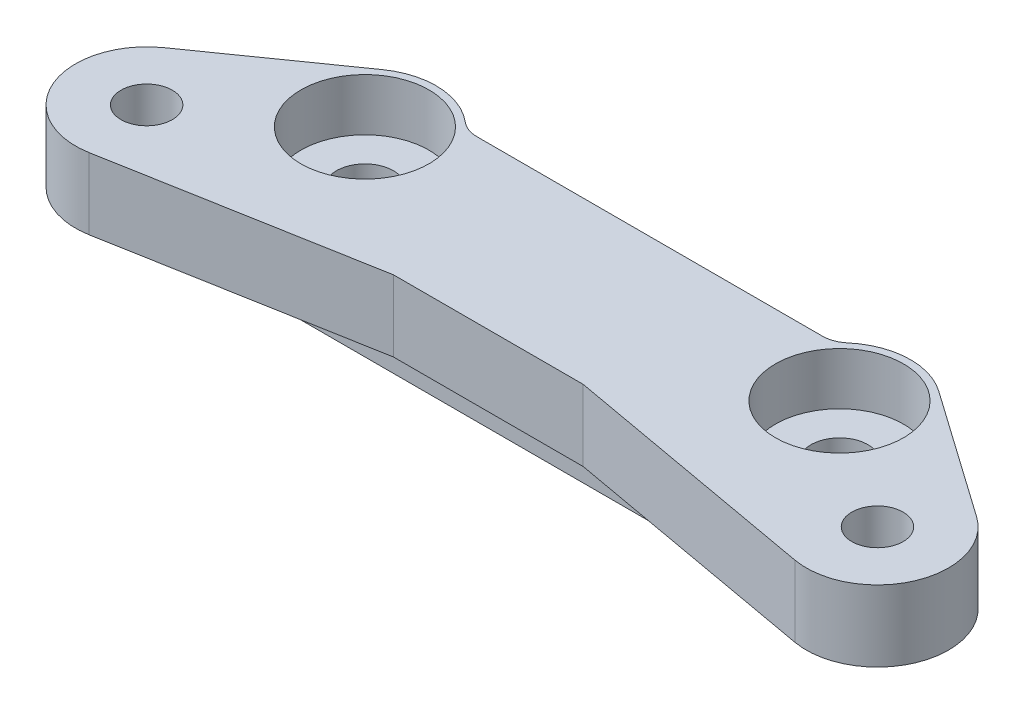
from build123d import *
from build123d.topology import SkipClean

# Parameters (mm, degrees)
BOSS_EXTRU_1_DEPTH      = 27
ESQUISSE1_3_R           = 15
ENL_V_MAT_EXTRU_1_DEPTH = 12
TROU_TARAUD_M12X1_251_D = 10.8
PER_AGE1_D              = 12
PER_AGE1_DEPTH          = 27
PER_AGE1_CBORE_D        = 27
PER_AGE1_CBORE_DEPTH    = 11
PER_AGE1_TIP            = 3.605163714
CONG_1_R                = 6


with BuildPart() as part:
    # Esquisse1 → Boss.-Extru.1 (new body)
    with BuildSketch(Plane(origin=(0, 0, 0), x_dir=(1, 0, 0), z_dir=(0, 1, 0))):
        with BuildLine():
            Line((-74.347688243, -14.763645971), (-20, -5))
            Line((-20, -5), (20, -5))
            Line((20, -5), (74.347688243, -14.763645971))
            ThreePointArc((74.347688243, -14.763645971), (90.842168324, -5.778786733), (85.632401093, 12.26709629))
            Line((85.632401093, 12.26709629), (58.632401093, 31.26709629))
            ThreePointArc((58.632401093, 31.26709629), (48.294734794, 33.902753792), (38.819660113, 29))
            Line((38.819660113, 29), (-38.819660113, 29))
            ThreePointArc((-38.819660113, 29), (-48.294734794, 33.902753792), (-58.632401093, 31.26709629))
            Line((-58.632401093, 31.26709629), (-85.632401093, 12.26709629))
            ThreePointArc((-85.632401093, 12.26709629), (-90.842168324, -5.778786733), (-74.347688243, -14.763645971))
        make_face()
    extrude(amount=BOSS_EXTRU_1_DEPTH)

    # Esquisse1_3 → Enl_v. mat.-Extru.1 (cut)
    with SkipClean():  # keep this step's faces unmerged: merging them makes the solid invalid here
        with BuildSketch(Plane(origin=(0, 0, 0), x_dir=(1, 0, 0), z_dir=(0, 1, 0))):
            with BuildLine():
                Line((-74.347688243, -14.763645971), (-20, -5))
                Line((-20, -5), (0, -5))
                Line((0, -5), (20, -5))
                Line((20, -5), (74.347688243, -14.763645971))
                ThreePointArc((74.347688243, -14.763645971), (63.157831676, 5.778786733), (85.632401093, 12.26709629))
                Line((85.632401093, 12.26709629), (58.632401093, 31.26709629))
                ThreePointArc((58.632401093, 31.26709629), (63.31326437, 25.910643371), (65, 19))
                ThreePointArc((65, 19), (60.606601718, 8.393398282), (50, 4))
                Line((50, 4), (-50, 4))
                ThreePointArc((-50, 4), (-64.300462306, 14.472663274), (-58.632401093, 31.26709629))
                Line((-58.632401093, 31.26709629), (-85.632401093, 12.26709629))
                ThreePointArc((-85.632401093, 12.26709629), (-70.089356629, 13.31326437), (-62, 0))
                ThreePointArc((-62, 0), (-65.493813048, -9.623287475), (-74.347688243, -14.763645971))
            make_face()
            with Locations((77, 0)):
                Circle(ESQUISSE1_3_R)
            with Locations((-77, 0)):
                Circle(ESQUISSE1_3_R)
        extrude(amount=ENL_V_MAT_EXTRU_1_DEPTH, mode=Mode.SUBTRACT)

    # Trou taraud_ M12x1.251 (through all)
    with Locations(Plane(origin=(0, 12, 0), x_dir=(-1, 0, 0), z_dir=(0, -1, 0))):
        with Locations((-77, 0), (77, 0)):
            Hole(TROU_TARAUD_M12X1_251_D / 2)

    # Per_age1
    with Locations(Plane(origin=(0, 27, 0), x_dir=(1, 0, 0), z_dir=(0, 1, 0))):
        with Locations((-50, 19), (50, 19)):
            CounterBoreHole(PER_AGE1_D / 2, PER_AGE1_CBORE_D / 2, PER_AGE1_CBORE_DEPTH, depth=PER_AGE1_DEPTH)
            with Locations((0, 0, -(PER_AGE1_DEPTH + PER_AGE1_TIP / 2))):  # 118° drill point
                Cone(0, PER_AGE1_D / 2, PER_AGE1_TIP, mode=Mode.SUBTRACT)

    # Cong_1
    cong_1_edges = [part.edges().sort_by_distance(p)[0] for p in [
        (38.819660113, 13.5, -29),
        (-38.819660113, 13.5, -29),
    ]]
    fillet(cong_1_edges, radius=CONG_1_R)


solid = part.part
